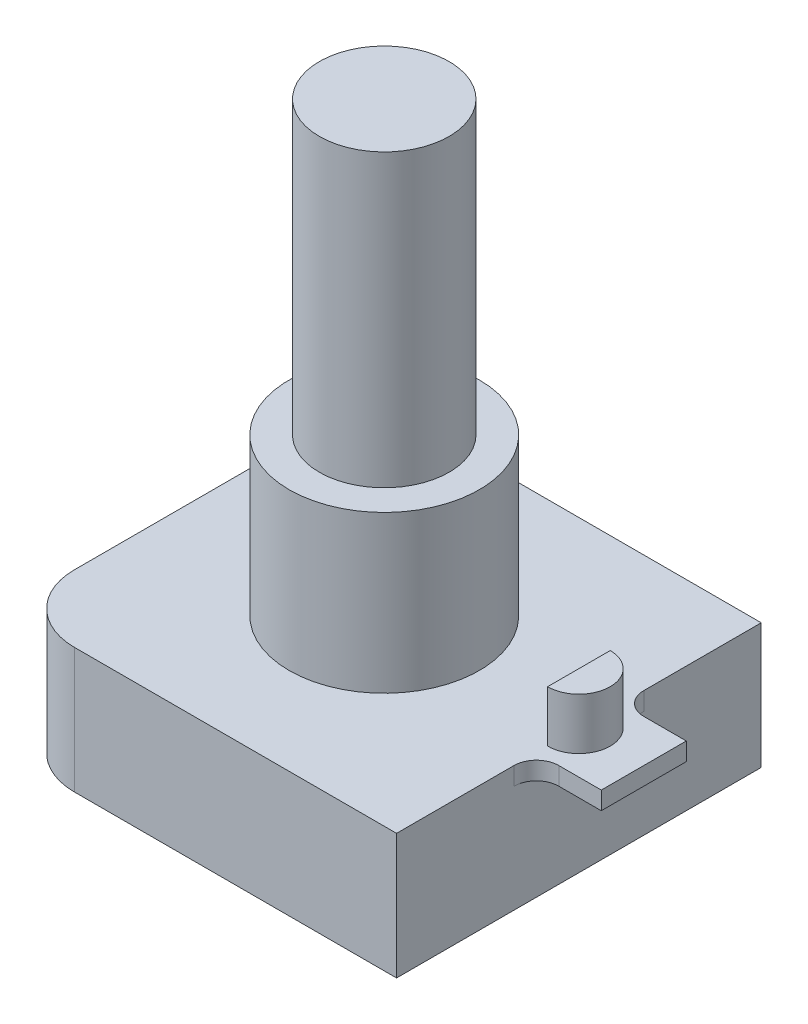
from build123d import *

# Parameters (mm, degrees)
SKETCH1_W           = 17.4
SKETCH1_H           = 16.3
BOSS_EXTRUDE1_DEPTH = 5.6
SKETCH2_R           = 4.25
BOSS_EXTRUDE2_DEPTH = 7
SKETCH3_R           = 2.9
BOSS_EXTRUDE3_DEPTH = 13
FILLET1_R           = 3
SKETCH4_W           = 3.8
SKETCH4_H           = 0.8
BOSS_EXTRUDE4_DEPTH = 2.9
FILLET2_R           = 1
BOSS_EXTRUDE5_DEPTH = 2.3


with BuildPart() as part:
    # Sketch1 → Boss-Extrude1 (new body)
    with BuildSketch(Plane(origin=(0, 0, 0), x_dir=(1, 0, 0), z_dir=(0, 1, 0))):
        Rectangle(SKETCH1_W, SKETCH1_H)
    extrude(amount=BOSS_EXTRUDE1_DEPTH)

    # Sketch2 → Boss-Extrude2 (add)
    with BuildSketch(Plane(origin=(0, 5.6, 0), x_dir=(1, 0, 0), z_dir=(0, 1, 0))):
        with Locations(Location((0, 0, 0), (0, 0, 270))):  # turned: the seam where the file's is
            Circle(SKETCH2_R)
    extrude(amount=BOSS_EXTRUDE2_DEPTH)

    # Sketch3 → Boss-Extrude3 (add)
    with BuildSketch(Plane(origin=(0, 12.6, 0), x_dir=(1, 0, 0), z_dir=(0, 1, 0))):
        with Locations(Location((0, 0, 0), (0, 0, 270))):  # turned: the seam where the file's is
            Circle(SKETCH3_R)
    extrude(amount=BOSS_EXTRUDE3_DEPTH)

    # Fillet1
    fillet1_edges = [part.edges().sort_by_distance(p)[0] for p in [
        (-8.7, 2.8, -8.15),
        (-8.7, 2.8, 8.15),
    ]]
    fillet(fillet1_edges, radius=FILLET1_R)

    # Sketch4 → Boss-Extrude4 (add)
    with BuildSketch(Plane(origin=(8.7, 0, 0), x_dir=(0, 0, -1), z_dir=(1, 0, 0))):
        with Locations((0, 5.2)):
            Rectangle(SKETCH4_W, SKETCH4_H)
    extrude(amount=BOSS_EXTRUDE4_DEPTH)

    # Fillet2
    fillet2_edges = [part.edges().sort_by_distance(p)[0] for p in [
        (8.7, 5.2, -1.9),
        (8.7, 5.2, 1.9),
    ]]
    fillet(fillet2_edges, radius=FILLET2_R)

    # Sketch5 → Boss-Extrude5 (add)
    with BuildSketch(Plane(origin=(0, 5.6, 0), x_dir=(1, 0, 0), z_dir=(0, 1, 0))):
        with BuildLine():
            Line((8.7, 1.4), (8.7, -1.4))
            ThreePointArc((8.7, -1.4), (10.1, 0), (8.7, 1.4))
        make_face()
    extrude(amount=BOSS_EXTRUDE5_DEPTH)


solid = part.part
